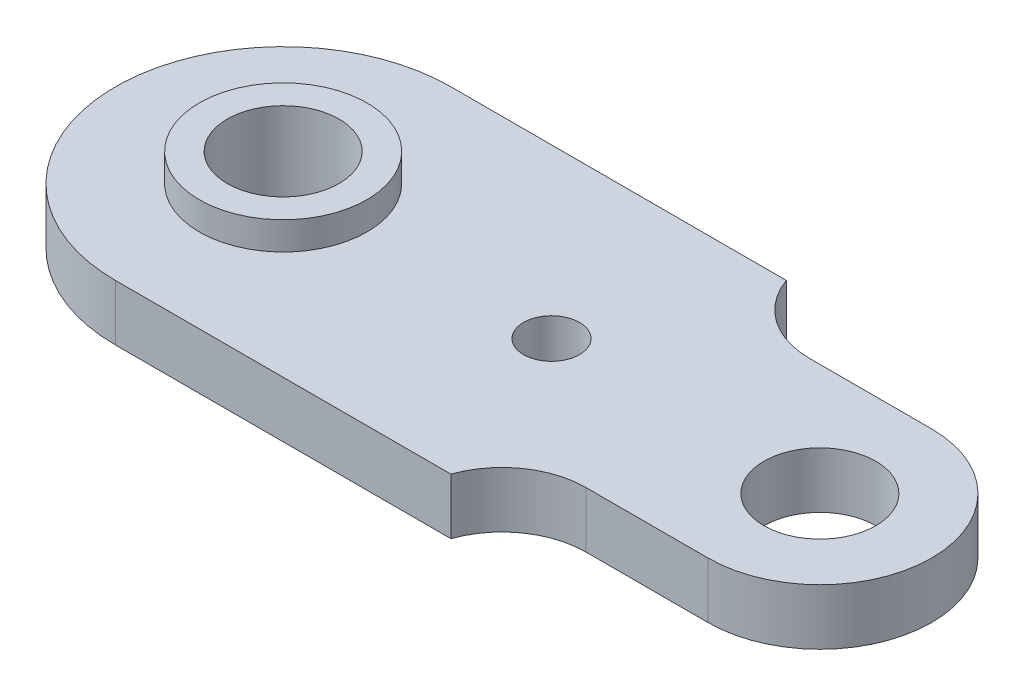
from build123d import *

# Parameters (mm, degrees)
SKETCH1_R           = 5
SKETCH1_R_2         = 10
BOSS_EXTRUDE1_DEPTH = 10
SKETCH2_R           = 15
SKETCH2_R_2         = 10
BOSS_EXTRUDE2_DEPTH = 5


with BuildPart() as part:
    # Sketch1 → Boss-Extrude1 (new body)
    with BuildSketch(Plane(origin=(0, 0, 0), x_dir=(1, 0, 0), z_dir=(0, 1, 0))):
        with BuildLine():
            Line((12, 30), (-48, 30))
            ThreePointArc((-48, 30), (-78, 0), (-48, -30))
            Line((-48, -30), (12, -30))
            ThreePointArc((12, -30), (17.481881586, -22.752551286), (26.142135624, -20))
            Line((26.142135624, -20), (48, -20))
            ThreePointArc((48, -20), (68, 0), (48, 20))
            Line((48, 20), (26.142135624, 20))
            ThreePointArc((26.142135624, 20), (17.481881586, 22.752551286), (12, 30))
        make_face()
        with Locations(Location((0, 0, 0), (0, 0, 270))):  # turned: the seam where the file's is
            Circle(SKETCH1_R, mode=Mode.SUBTRACT)
        with Locations(Location((-48, 0, 0), (0, 0, 270))):  # turned: the seam where the file's is
            Circle(SKETCH1_R_2, mode=Mode.SUBTRACT)
        with Locations(Location((48, 0, 0), (0, 0, 270))):  # turned: the seam where the file's is
            Circle(SKETCH1_R_2, mode=Mode.SUBTRACT)
    extrude(amount=BOSS_EXTRUDE1_DEPTH)

    # Sketch2 → Boss-Extrude2 (add)
    with BuildSketch(Plane(origin=(0, 10, 0), x_dir=(1, 0, 0), z_dir=(0, 1, 0))):
        with Locations(Location((-48, 0, 0), (0, 0, 270))):  # turned: the seam where the file's is
            Circle(SKETCH2_R)
        with Locations(Location((-48, 0, 0), (0, 0, 270))):  # turned: the seam where the file's is
            Circle(SKETCH2_R_2, mode=Mode.SUBTRACT)
    extrude(amount=BOSS_EXTRUDE2_DEPTH)


solid = part.part
